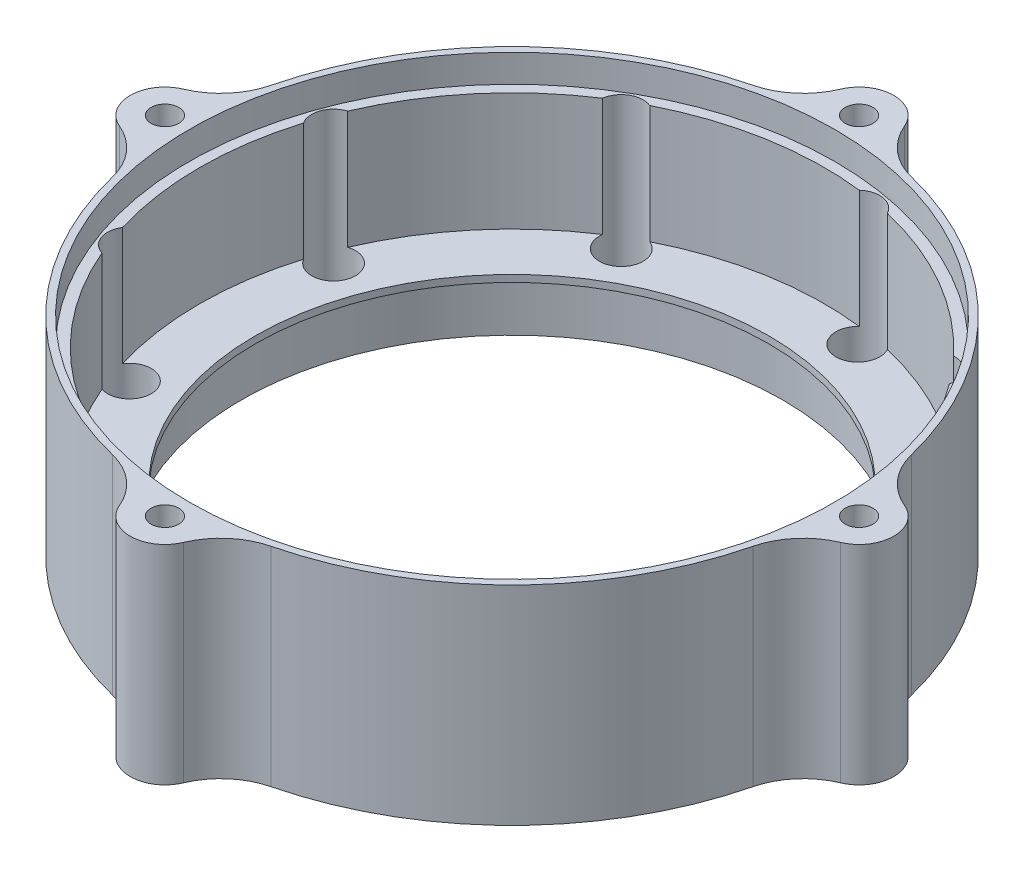
from build123d import *
from build123d.topology import SkipClean

# Parameters (mm, degrees)
SKETCH1_R            = 50
BOSS_EXTRUDE1_DEPTH  = 5
SKETCH2_R            = 3
BOSS_EXTRUDE2_DEPTH  = 30
SKETCH3_R            = 50
BOSS_EXTRUDE3_DEPTH  = 28
SKETCH4_R            = 39
CUT_EXTRUDE1_DEPTH   = 6
SKETCH5_R            = 3
CUT_EXTRUDE2_DEPTH   = 44
SKETCH6_R            = 50
SKETCH6_R_2          = 39
BOSS_EXTRUDE4_DEPTH  = 3
SKETCH7_R            = 47
SKETCH7_R_2          = 46
CUT_EXTRUDE3_DEPTH   = 4
SKETCH8_R            = 39
SKETCH8_R_2          = 37
BOSS_EXTRUDE5_DEPTH  = 1
SKETCH9_R            = 5
SKETCH9_R_2          = 2
BOSS_EXTRUDE6_DEPTH  = 33
FILLET1_R            = 5
SKETCH10_R           = 3.15
CUT_EXTRUDE6_DEPTH   = 2.5
SKETCH11_R           = 47.15
CUT_EXTRUDE7_DEPTH   = 4
SKETCH12_R           = 39
SKETCH12_R_2         = 3.15
BOSS_EXTRUDE7_DEPTH  = 7
SKETCH13_R           = 39
SKETCH13_R_2         = 37
BOSS_EXTRUDE9_DEPTH  = 1
SKETCH14_R           = 39
SKETCH14_R_2         = 37
CUT_EXTRUDE8_DEPTH   = 1
SKETCH15_R           = 3.15
BOSS_EXTRUDE10_DEPTH = 2.9
SKETCH16_R           = 57
CUT_EXTRUDE9_DEPTH   = 3
BOSS_EXTRUDE11_DEPTH = 17
CUT_EXTRUDE13_START  = -30
SKETCH18_R           = 47.5
SKETCH18_R_2         = 2
CUT_EXTRUDE13_DEPTH  = 30
SKETCH19_R           = 47.15
SKETCH19_R_2         = 46.15
BOSS_EXTRUDE12_DEPTH = 21
SKETCH20_R           = 46.5
SKETCH20_R_2         = 46.15
CUT_EXTRUDE14_DEPTH  = 4
SKETCH21_R           = 2
BOSS_EXTRUDE14_DEPTH = 30
FILLET2_R            = 10


with BuildPart() as part:
    # Sketch1 → Boss-Extrude1 (new body)
    with BuildSketch(Plane(origin=(0, 0, 0), x_dir=(1, 0, 0), z_dir=(0, 1, 0))):
        with Locations(Location((0, 0, 0), (0, 0, 270))):
            Circle(SKETCH1_R)
    extrude(amount=BOSS_EXTRUDE1_DEPTH)

    # Sketch2 → Boss-Extrude2 (add)
    with BuildSketch(Plane(origin=(0, 5, 0), x_dir=(1, 0, 0), z_dir=(0, 1, 0))):
        with Locations(Location((43, 0, 0), (0, 0, 270))):
            Circle(SKETCH2_R)
        with Locations(Location((32.939911054, -27.639867217, 0), (0, 0, 270))):
            Circle(SKETCH2_R)
        with Locations(Location((7.46687164, -42.34673338, 0), (0, 0, 270))):
            Circle(SKETCH2_R)
        with Locations(Location((-21.5, -37.239092363, 0), (0, 0, 270))):
            Circle(SKETCH2_R)
        with Locations(Location((-40.406782694, -14.706866163, 0), (0, 0, 270))):
            Circle(SKETCH2_R)
        with Locations(Location((-40.406782694, 14.706866163, 0), (0, 0, 270))):
            Circle(SKETCH2_R)
        with Locations(Location((-21.5, 37.239092363, 0), (0, 0, 270))):
            Circle(SKETCH2_R)
        with Locations(Location((7.46687164, 42.34673338, 0), (0, 0, 270))):
            Circle(SKETCH2_R)
        with Locations(Location((32.939911054, 27.639867217, 0), (0, 0, 270))):
            Circle(SKETCH2_R)
    extrude(amount=BOSS_EXTRUDE2_DEPTH)

    # Sketch3 → Boss-Extrude3 (add)
    with BuildSketch(Plane(origin=(0, 5, 0), x_dir=(1, 0, 0), z_dir=(0, 1, 0))):
        with Locations(Location((0, 0, 0), (0, 0, 270))):
            Circle(SKETCH3_R)
        with BuildLine():
            ThreePointArc((45.918604651, 2.735278211), (43.225860556, 15.732926593), (36.933894872, 27.42056545))
            ThreePointArc((36.933894872, 27.42056545), (36.004088827, 30.211017655), (33.417488986, 31.611254798))
            ThreePointArc((33.417488986, 31.611254798), (23, 39.837168574), (10.667405207, 44.746021791))
            ThreePointArc((10.667405207, 44.746021791), (8.16146435, 46.285964392), (5.27995883, 45.695973945))
            ThreePointArc((5.27995883, 45.695973945), (-7.987816173, 45.301156639), (-20.590481909, 41.13431724))
            ThreePointArc((-20.590481909, 41.13431724), (-23.5, 40.703193978), (-25.328122743, 38.399039029))
            ThreePointArc((-25.328122743, 38.399039029), (-35.238044383, 29.568230046), (-42.213853702, 18.275408495))
            ThreePointArc((-42.213853702, 18.275408495), (-44.165553177, 16.074946736), (-44.084894193, 13.134766994))
            ThreePointArc((-44.084894193, 13.134766994), (-46, 0), (-44.084894193, -13.134766994))
            ThreePointArc((-44.084894193, -13.134766994), (-44.165553177, -16.074946736), (-42.213853702, -18.275408495))
            ThreePointArc((-42.213853702, -18.275408495), (-35.238044383, -29.568230046), (-25.328122743, -38.399039029))
            ThreePointArc((-25.328122743, -38.399039029), (-23.5, -40.703193978), (-20.590481909, -41.13431724))
            ThreePointArc((-20.590481909, -41.13431724), (-7.987816173, -45.301156639), (5.27995883, -45.695973945))
            ThreePointArc((5.27995883, -45.695973945), (8.16146435, -46.285964392), (10.667405207, -44.746021791))
            ThreePointArc((10.667405207, -44.746021791), (23, -39.837168574), (33.417488986, -31.611254798))
            ThreePointArc((33.417488986, -31.611254798), (36.004088827, -30.211017655), (36.933894872, -27.42056545))
            ThreePointArc((36.933894872, -27.42056545), (43.225860556, -15.732926593), (45.918604651, -2.735278211))
            ThreePointArc((45.918604651, -2.735278211), (47, 0), (45.918604651, 2.735278211))
        make_face(mode=Mode.SUBTRACT)
    extrude(amount=BOSS_EXTRUDE3_DEPTH)

    # Sketch4 → Cut-Extrude1 (cut)
    with BuildSketch(Plane(origin=(0, 5, 0), x_dir=(1, 0, 0), z_dir=(0, 1, 0))):
        with Locations(Location((0, 0, 0), (0, 0, 270))):
            Circle(SKETCH4_R)
    extrude(amount=-CUT_EXTRUDE1_DEPTH, mode=Mode.SUBTRACT)

    # Sketch5 → Cut-Extrude2 (cut, symmetric)
    with BuildSketch(Plane(origin=(0, 5, 0), x_dir=(1, 0, 0), z_dir=(0, 1, 0))):
        with Locations(Location((43, 0, 0), (0, 0, 270))):
            Circle(SKETCH5_R)
        with Locations(Location((32.939911054, -27.639867217, 0), (0, 0, 270))):
            Circle(SKETCH5_R)
        with Locations(Location((7.46687164, -42.34673338, 0), (0, 0, 270))):
            Circle(SKETCH5_R)
        with Locations(Location((-21.5, -37.239092363, 0), (0, 0, 270))):
            Circle(SKETCH5_R)
        with Locations(Location((-40.406782694, -14.706866163, 0), (0, 0, 270))):
            Circle(SKETCH5_R)
        with Locations(Location((-40.406782694, 14.706866163, 0), (0, 0, 270))):
            Circle(SKETCH5_R)
        with Locations(Location((-21.5, 37.239092363, 0), (0, 0, 270))):
            Circle(SKETCH5_R)
        with Locations(Location((7.46687164, 42.34673338, 0), (0, 0, 270))):
            Circle(SKETCH5_R)
        with Locations(Location((32.939911054, 27.639867217, 0), (0, 0, 270))):
            Circle(SKETCH5_R)
    extrude(amount=CUT_EXTRUDE2_DEPTH, both=True, mode=Mode.SUBTRACT)

    # Sketch6 → Boss-Extrude4 (add)
    with BuildSketch(Plane.XZ):
        with Locations(Location((0, 0, 0), (0, 0, 90))):
            Circle(SKETCH6_R)
        with Locations(Location((0, 0, 0), (0, 0, 90))):
            Circle(SKETCH6_R_2, mode=Mode.SUBTRACT)
    extrude(amount=-BOSS_EXTRUDE4_DEPTH)

    # Sketch7 → Cut-Extrude3 (cut)
    with BuildSketch(Plane(origin=(0, 33, 0), x_dir=(1, 0, 0), z_dir=(0, 1, 0))):
        with Locations(Location((0, 0, 0), (0, 0, 270))):
            Circle(SKETCH7_R)
        Circle(SKETCH7_R_2, mode=Mode.SUBTRACT)
    extrude(amount=-CUT_EXTRUDE3_DEPTH, mode=Mode.SUBTRACT)

    # Sketch8 → Boss-Extrude5 (add)
    with BuildSketch(Plane.XZ):
        with Locations(Location((0, 0, 0), (0, 0, 90))):
            Circle(SKETCH8_R)
        with Locations(Location((0, 0, 0), (0, 0, 270))):
            Circle(SKETCH8_R_2, mode=Mode.SUBTRACT)
    extrude(amount=-BOSS_EXTRUDE5_DEPTH)

    # Sketch9 → Boss-Extrude6 (add)
    with BuildSketch(Plane(origin=(0, 33, 0), x_dir=(1, 0, 0), z_dir=(0, 1, 0))):
        with Locations((52, 0)):
            Circle(SKETCH9_R)
        with Locations(Location((52, 0, 0), (0, 0, 270))):
            Circle(SKETCH9_R_2, mode=Mode.SUBTRACT)
        with Locations((-52, 0)):
            Circle(SKETCH9_R)
        with Locations(Location((-52, 0, 0), (0, 0, 270))):
            Circle(SKETCH9_R_2, mode=Mode.SUBTRACT)
        with Locations((0, 52)):
            Circle(SKETCH9_R)
        with Locations(Location((0, 52, 0), (0, 0, 270))):
            Circle(SKETCH9_R_2, mode=Mode.SUBTRACT)
        with Locations((0, -52)):
            Circle(SKETCH9_R)
        with Locations(Location((0, -52, 0), (0, 0, 270))):
            Circle(SKETCH9_R_2, mode=Mode.SUBTRACT)
    extrude(amount=-BOSS_EXTRUDE6_DEPTH)

    # Fillet1
    fillet1_edges = [part.edges().sort_by_distance(p)[0] for p in [
        (49.798076923, 16.5, 4.489046086),
        (49.798076923, 16.5, -4.489046086),
        (-49.798076923, 16.5, -4.489046086),
        (-49.798076923, 16.5, 4.489046086),
        (4.489046086, 16.5, -49.798076923),
        (-4.489046086, 16.5, -49.798076923),
        (-4.489046086, 16.5, 49.798076923),
        (4.489046086, 16.5, 49.798076923),
    ]]
    fillet(fillet1_edges, radius=FILLET1_R)

    # Sketch10 → Cut-Extrude6 (cut)
    with BuildSketch(Plane(origin=(0, 5, 0), x_dir=(1, 0, 0), z_dir=(0, 1, 0))):
        with Locations(Location((32.939911054, -27.639867217, 0), (0, 0, 270))):
            Circle(SKETCH10_R)
        with Locations(Location((43, 0, 0), (0, 0, 270))):
            Circle(SKETCH10_R)
        with Locations(Location((7.46687164, -42.34673338, 0), (0, 0, 270))):
            Circle(SKETCH10_R)
        with Locations(Location((-21.5, -37.239092363, 0), (0, 0, 270))):
            Circle(SKETCH10_R)
        with Locations(Location((-40.406782694, -14.706866163, 0), (0, 0, 270))):
            Circle(SKETCH10_R)
        with Locations(Location((-40.406782694, 14.706866163, 0), (0, 0, 270))):
            Circle(SKETCH10_R)
        with Locations(Location((-21.5, 37.239092363, 0), (0, 0, 270))):
            Circle(SKETCH10_R)
        with Locations(Location((7.46687164, 42.34673338, 0), (0, 0, 270))):
            Circle(SKETCH10_R)
        with Locations(Location((32.939911054, 27.639867217, 0), (0, 0, 270))):
            Circle(SKETCH10_R)
    extrude(amount=-CUT_EXTRUDE6_DEPTH, mode=Mode.SUBTRACT)

    # Sketch11 → Cut-Extrude7 (cut)
    with BuildSketch(Plane(origin=(0, 33, 0), x_dir=(1, 0, 0), z_dir=(0, 1, 0))):
        with Locations(Location((0, 0, 0), (0, 0, 270))):
            Circle(SKETCH11_R)
    extrude(amount=-CUT_EXTRUDE7_DEPTH, mode=Mode.SUBTRACT)

    # Sketch12 → Boss-Extrude7 (add)
    with BuildSketch(Plane(origin=(0, 5, 0), x_dir=(1, 0, 0), z_dir=(0, 1, 0))):
        with BuildLine():
            ThreePointArc((36.933894872, -27.42056545), (43.225860556, -15.732926593), (45.918604651, -2.735278211))
            ThreePointArc((45.918604651, -2.735278211), (47, 0), (45.918604651, 2.735278211))
            ThreePointArc((45.918604651, 2.735278211), (43.225860556, 15.732926593), (36.933894872, 27.42056545))
            ThreePointArc((36.933894872, 27.42056545), (36.004088827, 30.211017655), (33.417488986, 31.611254798))
            ThreePointArc((33.417488986, 31.611254798), (23, 39.837168574), (10.667405207, 44.746021791))
            ThreePointArc((10.667405207, 44.746021791), (8.16146435, 46.285964392), (5.27995883, 45.695973945))
            ThreePointArc((5.27995883, 45.695973945), (-7.987816173, 45.301156639), (-20.590481909, 41.13431724))
            ThreePointArc((-20.590481909, 41.13431724), (-23.5, 40.703193978), (-25.328122743, 38.399039029))
            ThreePointArc((-25.328122743, 38.399039029), (-35.238044383, 29.568230046), (-42.213853702, 18.275408495))
            ThreePointArc((-42.213853702, 18.275408495), (-44.165553177, 16.074946736), (-44.084894193, 13.134766994))
            ThreePointArc((-44.084894193, 13.134766994), (-46, 0), (-44.084894193, -13.134766994))
            ThreePointArc((-44.084894193, -13.134766994), (-44.165553177, -16.074946736), (-42.213853702, -18.275408495))
            ThreePointArc((-42.213853702, -18.275408495), (-35.238044383, -29.568230046), (-25.328122743, -38.399039029))
            ThreePointArc((-25.328122743, -38.399039029), (-23.5, -40.703193978), (-20.590481909, -41.13431724))
            ThreePointArc((-20.590481909, -41.13431724), (-7.987816173, -45.301156639), (5.27995883, -45.695973945))
            ThreePointArc((5.27995883, -45.695973945), (8.16146435, -46.285964392), (10.667405207, -44.746021791))
            ThreePointArc((10.667405207, -44.746021791), (23, -39.837168574), (33.417488986, -31.611254798))
            ThreePointArc((33.417488986, -31.611254798), (36.004088827, -30.211017655), (36.933894872, -27.42056545))
        make_face()
        with Locations(Location((0, 0, 0), (0, 0, 270))):
            Circle(SKETCH12_R, mode=Mode.SUBTRACT)
        with Locations(Location((32.939911054, -27.639867217, 0), (0, 0, 270))):
            Circle(SKETCH12_R_2, mode=Mode.SUBTRACT)
        with Locations(Location((43, 0, 0), (0, 0, 270))):
            Circle(SKETCH12_R_2, mode=Mode.SUBTRACT)
        with Locations(Location((7.46687164, -42.34673338, 0), (0, 0, 270))):
            Circle(SKETCH12_R_2, mode=Mode.SUBTRACT)
        with Locations(Location((-21.5, -37.239092363, 0), (0, 0, 270))):
            Circle(SKETCH12_R_2, mode=Mode.SUBTRACT)
        with Locations(Location((-40.406782694, -14.706866163, 0), (0, 0, 270))):
            Circle(SKETCH12_R_2, mode=Mode.SUBTRACT)
        with Locations(Location((-40.406782694, 14.706866163, 0), (0, 0, 270))):
            Circle(SKETCH12_R_2, mode=Mode.SUBTRACT)
        with Locations(Location((-21.5, 37.239092363, 0), (0, 0, 270))):
            Circle(SKETCH12_R_2, mode=Mode.SUBTRACT)
        with Locations(Location((7.46687164, 42.34673338, 0), (0, 0, 270))):
            Circle(SKETCH12_R_2, mode=Mode.SUBTRACT)
        with Locations(Location((32.939911054, 27.639867217, 0), (0, 0, 270))):
            Circle(SKETCH12_R_2, mode=Mode.SUBTRACT)
    extrude(amount=BOSS_EXTRUDE7_DEPTH)

    # Sketch13 → Boss-Extrude9 (add)
    with BuildSketch(Plane(origin=(0, 12, 0), x_dir=(1, 0, 0), z_dir=(0, 1, 0))):
        with Locations(Location((0, 0, 0), (0, 0, 270))):
            Circle(SKETCH13_R)
        with Locations(Location((0, 0, 0), (0, 0, 90))):
            Circle(SKETCH13_R_2, mode=Mode.SUBTRACT)
    extrude(amount=-BOSS_EXTRUDE9_DEPTH)

    # Sketch14 → Cut-Extrude8 (cut)
    with BuildSketch(Plane.XZ):
        with Locations(Location((0, 0, 0), (0, 0, 90))):
            Circle(SKETCH14_R)
        with Locations(Location((0, 0, 0), (0, 0, 90))):
            Circle(SKETCH14_R_2, mode=Mode.SUBTRACT)
    extrude(amount=-CUT_EXTRUDE8_DEPTH, mode=Mode.SUBTRACT)

    # Sketch15 → Boss-Extrude10 (add)
    with BuildSketch(Plane(origin=(0, 2.5, 0), x_dir=(1, 0, 0), z_dir=(0, 1, 0))):
        with Locations(Location((43, 0, 0), (0, 0, 270))):
            Circle(SKETCH15_R)
        with Locations(Location((32.939911054, -27.639867217, 0), (0, 0, 270))):
            Circle(SKETCH15_R)
        with Locations(Location((7.46687164, -42.34673338, 0), (0, 0, 270))):
            Circle(SKETCH15_R)
        with Locations(Location((-21.5, -37.239092363, 0), (0, 0, 270))):
            Circle(SKETCH15_R)
        with Locations(Location((-40.406782694, -14.706866163, 0), (0, 0, 270))):
            Circle(SKETCH15_R)
        with Locations(Location((-40.406782694, 14.706866163, 0), (0, 0, 270))):
            Circle(SKETCH15_R)
        with Locations(Location((-21.5, 37.239092363, 0), (0, 0, 270))):
            Circle(SKETCH15_R)
        with Locations(Location((7.46687164, 42.34673338, 0), (0, 0, 270))):
            Circle(SKETCH15_R)
        with Locations(Location((32.939911054, 27.639867217, 0), (0, 0, 270))):
            Circle(SKETCH15_R)
    extrude(amount=BOSS_EXTRUDE10_DEPTH)

    # Sketch16 → Cut-Extrude9 (cut)
    with BuildSketch(Plane(origin=(0, 0, 0), x_dir=(-1, 0, 0), z_dir=(0, -1, 0))):
        Circle(SKETCH16_R)
    extrude(amount=-CUT_EXTRUDE9_DEPTH, mode=Mode.SUBTRACT)

    # Sketch17 → Boss-Extrude11 (add)
    with BuildSketch(Plane(origin=(0, 29, 0), x_dir=(1, 0, 0), z_dir=(0, 1, 0))):
        with BuildLine():
            ThreePointArc((36.933894872, -27.42056545), (43.225860556, -15.732926593), (45.918604651, -2.735278211))
            ThreePointArc((45.918604651, -2.735278211), (47, 0), (45.918604651, 2.735278211))
            ThreePointArc((45.918604651, 2.735278211), (43.225860556, 15.732926593), (36.933894872, 27.42056545))
            ThreePointArc((36.933894872, 27.42056545), (36.004088827, 30.211017655), (33.417488986, 31.611254798))
            ThreePointArc((33.417488986, 31.611254798), (23, 39.837168574), (10.667405207, 44.746021791))
            ThreePointArc((10.667405207, 44.746021791), (8.16146435, 46.285964392), (5.27995883, 45.695973945))
            ThreePointArc((5.27995883, 45.695973945), (-7.987816173, 45.301156639), (-20.590481909, 41.13431724))
            ThreePointArc((-20.590481909, 41.13431724), (-23.5, 40.703193978), (-25.328122743, 38.399039029))
            ThreePointArc((-25.328122743, 38.399039029), (-35.238044383, 29.568230046), (-42.213853702, 18.275408495))
            ThreePointArc((-42.213853702, 18.275408495), (-44.165553177, 16.074946736), (-44.084894193, 13.134766994))
            ThreePointArc((-44.084894193, 13.134766994), (-46, 0), (-44.084894193, -13.134766994))
            ThreePointArc((-44.084894193, -13.134766994), (-44.165553177, -16.074946736), (-42.213853702, -18.275408495))
            ThreePointArc((-42.213853702, -18.275408495), (-35.238044383, -29.568230046), (-25.328122743, -38.399039029))
            ThreePointArc((-25.328122743, -38.399039029), (-23.5, -40.703193978), (-20.590481909, -41.13431724))
            ThreePointArc((-20.590481909, -41.13431724), (-7.987816173, -45.301156639), (5.27995883, -45.695973945))
            ThreePointArc((5.27995883, -45.695973945), (8.16146435, -46.285964392), (10.667405207, -44.746021791))
            ThreePointArc((10.667405207, -44.746021791), (23, -39.837168574), (33.417488986, -31.611254798))
            ThreePointArc((33.417488986, -31.611254798), (36.004088827, -30.211017655), (36.933894872, -27.42056545))
        make_face()
        with BuildLine():
            ThreePointArc((36.018898513, 26.974783593), (42.286167935, 15.39090645), (44.931133721, 2.488618603))
            ThreePointArc((44.931133721, 2.488618603), (45.828919513, 1.385537581), (46.15, 0))
            ThreePointArc((46.15, 0), (45.828919513, -1.385537581), (44.931133721, -2.488618603))
            ThreePointArc((44.931133721, -2.488618603), (42.286167935, -15.39090645), (36.018898513, -26.974783593))
            ThreePointArc((36.018898513, -26.974783593), (36.072107607, -27.305435233), (36.089911054, -27.639867217))
            ThreePointArc((36.089911054, -27.639867217), (35.124344083, -29.909394115), (32.819592107, -30.787568497))
            ThreePointArc((32.819592107, -30.787568497), (22.5, -38.97114317), (10.253020386, -43.816384755))
            ThreePointArc((10.253020386, -43.816384755), (8.013863399, -45.448877802), (5.351398596, -44.680672925))
            ThreePointArc((5.351398596, -44.680672925), (-7.814167995, -44.316348886), (-20.31035993, -40.155812525))
            ThreePointArc((-20.31035993, -40.155812525), (-23.075, -39.967072385), (-24.620773791, -37.667193922))
            ThreePointArc((-24.620773791, -37.667193922), (-34.47199994, -28.925442436), (-41.37029711, -17.705889332))
            ThreePointArc((-41.37029711, -17.705889332), (-43.366814449, -15.784229614), (-43.072612492, -13.028816258))
            ThreePointArc((-43.072612492, -13.028816258), (-45, 0), (-43.072612492, 13.028816258))
            ThreePointArc((-43.072612492, 13.028816258), (-43.366814449, 15.784229614), (-41.37029711, 17.705889332))
            ThreePointArc((-41.37029711, 17.705889332), (-34.47199994, 28.925442436), (-24.620773791, 37.667193922))
            ThreePointArc((-24.620773791, 37.667193922), (-23.075, 39.967072385), (-20.31035993, 40.155812525))
            ThreePointArc((-20.31035993, 40.155812525), (-7.814167995, 44.316348886), (5.351398596, 44.680672925))
            ThreePointArc((5.351398596, 44.680672925), (8.013863399, 45.448877802), (10.253020386, 43.816384755))
            ThreePointArc((10.253020386, 43.816384755), (22.5, 38.97114317), (32.819592107, 30.787568497))
            ThreePointArc((32.819592107, 30.787568497), (35.124344083, 29.909394115), (36.089911054, 27.639867217))
            ThreePointArc((36.089911054, 27.639867217), (36.072107607, 27.305435233), (36.018898513, 26.974783593))
        make_face(mode=Mode.SUBTRACT)
    extrude(amount=-BOSS_EXTRUDE11_DEPTH)

    # Sketch18 → Cut-Extrude13 (cut)
    with BuildSketch(Plane(origin=(0, 33, 0), x_dir=(1, 0, 0), z_dir=(0, 1, 0)).offset(CUT_EXTRUDE13_START)):
        with BuildLine():
            add(Edge.make_bspline(
                [(53.0625, -4.885805333), (52.836073182, -4.935045627), (52.60866978, -4.997686057), (52.381651265, -5.074241405), (52.156546198, -5.165006302), (51.934986665, -5.269967693), (51.501885278, -5.507764581), (51.290356485, -5.640638601), (51.085615173, -5.787065735), (50.889258423, -5.946379033), (50.702733406, -6.117577737), (50.352444061, -6.480535262), (50.188590734, -6.672210163), (50.036862124, -6.873218404), (49.898196618, -7.082096871), (49.77319943, -7.297246207), (49.550370532, -7.738331674), (49.452724639, -7.964331149), (49.369507547, -8.193413917), (49.300676289, -8.423927884), (49.245878786, -8.654336895), (49.204545455, -8.883282423)],
                knots=[0, 0, 0, 0, 0, 0, 0, 0.249829575, 0.249829575, 0.249829575, 0.249829575, 0.249829575, 0.5, 0.5, 0.5, 0.5, 0.5, 0.749170225, 0.749170225, 0.749170225, 0.749170225, 0.749170225, 1, 1, 1, 1, 1, 1, 1], degree=6))
            ThreePointArc((53.0625, -4.885805333), (57, 0), (53.0625, 4.885805333))
            add(Edge.make_bspline(
                [(49.204545455, 8.883282423), (49.245713967, 8.655249829), (49.300239483, 8.425765409), (49.368684808, 8.196171496), (49.451398669, 7.967985224), (49.548425977, 7.742838112), (49.770692859, 7.301565403), (49.895971396, 7.085451489), (50.035035531, 6.875639486), (50.18727545, 6.673749151), (50.351742417, 6.481262281), (50.702031762, 6.118304756), (50.887767114, 5.947748139), (51.083260483, 5.788977152), (51.287083003, 5.642981547), (51.497657818, 5.510422952), (51.930552122, 5.272071051), (52.152941515, 5.166461197), (52.378924642, 5.07516155), (52.606848925, 4.998187841), (52.835166676, 4.935242762), (53.0625, 4.885805333)],
                knots=[0, 0, 0, 0, 0, 0, 0, 0.249829575, 0.249829575, 0.249829575, 0.249829575, 0.249829575, 0.5, 0.5, 0.5, 0.5, 0.5, 0.749170225, 0.749170225, 0.749170225, 0.749170225, 0.749170225, 1, 1, 1, 1, 1, 1, 1], degree=6))
            ThreePointArc((49.204545455, 8.883282423), (35.355339059, 35.355339059), (8.883282423, 49.204545455))
            add(Edge.make_bspline(
                [(4.885805333, 53.0625), (4.935045627, 52.836073182), (4.997686057, 52.60866978), (5.074241405, 52.381651265), (5.165006302, 52.156546198), (5.269967693, 51.934986665), (5.507764581, 51.501885278), (5.640638601, 51.290356485), (5.787065735, 51.085615173), (5.946379033, 50.889258423), (6.117577737, 50.702733406), (6.480535262, 50.352444061), (6.672210163, 50.188590734), (6.873218404, 50.036862124), (7.082096871, 49.898196618), (7.297246207, 49.77319943), (7.738331674, 49.550370532), (7.964331149, 49.452724639), (8.193413917, 49.369507547), (8.423927884, 49.300676289), (8.654336895, 49.245878786), (8.883282423, 49.204545455)],
                knots=[0, 0, 0, 0, 0, 0, 0, 0.249829575, 0.249829575, 0.249829575, 0.249829575, 0.249829575, 0.5, 0.5, 0.5, 0.5, 0.5, 0.749170225, 0.749170225, 0.749170225, 0.749170225, 0.749170225, 1, 1, 1, 1, 1, 1, 1], degree=6))
            ThreePointArc((4.885805333, 53.0625), (0, 57), (-4.885805333, 53.0625))
            add(Edge.make_bspline(
                [(-8.883282423, 49.204545455), (-8.655249829, 49.245713967), (-8.425765409, 49.300239483), (-8.196171496, 49.368684808), (-7.967985224, 49.451398669), (-7.742838112, 49.548425977), (-7.301565403, 49.770692859), (-7.085451489, 49.895971396), (-6.875639486, 50.035035531), (-6.673749151, 50.18727545), (-6.481262281, 50.351742417), (-6.118304756, 50.702031762), (-5.947748139, 50.887767114), (-5.788977152, 51.083260483), (-5.642981547, 51.287083003), (-5.510422952, 51.497657818), (-5.272071051, 51.930552122), (-5.166461197, 52.152941515), (-5.07516155, 52.378924642), (-4.998187841, 52.606848925), (-4.935242762, 52.835166676), (-4.885805333, 53.0625)],
                knots=[0, 0, 0, 0, 0, 0, 0, 0.249829575, 0.249829575, 0.249829575, 0.249829575, 0.249829575, 0.5, 0.5, 0.5, 0.5, 0.5, 0.749170225, 0.749170225, 0.749170225, 0.749170225, 0.749170225, 1, 1, 1, 1, 1, 1, 1], degree=6))
            ThreePointArc((-8.883282423, 49.204545455), (-35.355339059, 35.355339059), (-49.204545455, 8.883282423))
            add(Edge.make_bspline(
                [(-53.0625, 4.885805333), (-52.836073182, 4.935045627), (-52.60866978, 4.997686057), (-52.381651265, 5.074241405), (-52.156546198, 5.165006302), (-51.934986665, 5.269967693), (-51.501885278, 5.507764581), (-51.290356485, 5.640638601), (-51.085615173, 5.787065735), (-50.889258423, 5.946379033), (-50.702733406, 6.117577737), (-50.352444061, 6.480535262), (-50.188590734, 6.672210163), (-50.036862124, 6.873218404), (-49.898196618, 7.082096871), (-49.77319943, 7.297246207), (-49.550370532, 7.738331674), (-49.452724639, 7.964331149), (-49.369507547, 8.193413917), (-49.300676289, 8.423927884), (-49.245878786, 8.654336895), (-49.204545455, 8.883282423)],
                knots=[0, 0, 0, 0, 0, 0, 0, 0.249829575, 0.249829575, 0.249829575, 0.249829575, 0.249829575, 0.5, 0.5, 0.5, 0.5, 0.5, 0.749170225, 0.749170225, 0.749170225, 0.749170225, 0.749170225, 1, 1, 1, 1, 1, 1, 1], degree=6))
            ThreePointArc((-53.0625, 4.885805333), (-57, 0), (-53.0625, -4.885805333))
            add(Edge.make_bspline(
                [(-49.204545455, -8.883282423), (-49.245713967, -8.655249829), (-49.300239483, -8.425765409), (-49.368684808, -8.196171496), (-49.451398669, -7.967985224), (-49.548425977, -7.742838112), (-49.770692859, -7.301565403), (-49.895971396, -7.085451489), (-50.035035531, -6.875639486), (-50.18727545, -6.673749151), (-50.351742417, -6.481262281), (-50.702031762, -6.118304756), (-50.887767114, -5.947748139), (-51.083260483, -5.788977152), (-51.287083003, -5.642981547), (-51.497657818, -5.510422952), (-51.930552122, -5.272071051), (-52.152941515, -5.166461197), (-52.378924642, -5.07516155), (-52.606848925, -4.998187841), (-52.835166676, -4.935242762), (-53.0625, -4.885805333)],
                knots=[0, 0, 0, 0, 0, 0, 0, 0.249829575, 0.249829575, 0.249829575, 0.249829575, 0.249829575, 0.5, 0.5, 0.5, 0.5, 0.5, 0.749170225, 0.749170225, 0.749170225, 0.749170225, 0.749170225, 1, 1, 1, 1, 1, 1, 1], degree=6))
            ThreePointArc((-49.204545455, -8.883282423), (-35.355339059, -35.355339059), (-8.883282423, -49.204545455))
            add(Edge.make_bspline(
                [(-8.883282423, -49.204545455), (-8.655249829, -49.245713967), (-8.425765409, -49.300239483), (-8.196171496, -49.368684808), (-7.967985224, -49.451398669), (-7.742838112, -49.548425977), (-7.301565403, -49.770692859), (-7.085451489, -49.895971396), (-6.875639486, -50.035035531), (-6.673749151, -50.18727545), (-6.481262281, -50.351742417), (-6.118304756, -50.702031762), (-5.947748139, -50.887767114), (-5.788977152, -51.083260483), (-5.642981547, -51.287083003), (-5.510422952, -51.497657818), (-5.272071051, -51.930552122), (-5.166461197, -52.152941515), (-5.07516155, -52.378924642), (-4.998187841, -52.606848925), (-4.935242762, -52.835166676), (-4.885805333, -53.0625)],
                knots=[0, 0, 0, 0, 0, 0, 0, 0.249829575, 0.249829575, 0.249829575, 0.249829575, 0.249829575, 0.5, 0.5, 0.5, 0.5, 0.5, 0.749170225, 0.749170225, 0.749170225, 0.749170225, 0.749170225, 1, 1, 1, 1, 1, 1, 1], degree=6))
            ThreePointArc((-4.885805333, -53.0625), (0, -57), (4.885805333, -53.0625))
            add(Edge.make_bspline(
                [(8.883282423, -49.204545455), (8.655249829, -49.245713967), (8.425765409, -49.300239483), (8.196171496, -49.368684808), (7.967985224, -49.451398669), (7.742838112, -49.548425977), (7.301565403, -49.770692859), (7.085451489, -49.895971396), (6.875639486, -50.035035531), (6.673749151, -50.18727545), (6.481262281, -50.351742417), (6.118304756, -50.702031762), (5.947748139, -50.887767114), (5.788977152, -51.083260483), (5.642981547, -51.287083003), (5.510422952, -51.497657818), (5.272071051, -51.930552122), (5.166461197, -52.152941515), (5.07516155, -52.378924642), (4.998187841, -52.606848925), (4.935242762, -52.835166676), (4.885805333, -53.0625)],
                knots=[0, 0, 0, 0, 0, 0, 0, 0.249829575, 0.249829575, 0.249829575, 0.249829575, 0.249829575, 0.5, 0.5, 0.5, 0.5, 0.5, 0.749170225, 0.749170225, 0.749170225, 0.749170225, 0.749170225, 1, 1, 1, 1, 1, 1, 1], degree=6))
            ThreePointArc((8.883282423, -49.204545455), (35.355339059, -35.355339059), (49.204545455, -8.883282423))
        make_face()
        with Locations(Location((0, 0, 0), (0, 0, 270))):
            Circle(SKETCH18_R, mode=Mode.SUBTRACT)
        with Locations((52, 0)):
            Circle(SKETCH18_R_2, mode=Mode.SUBTRACT)
        with Locations((0, 52)):
            Circle(SKETCH18_R_2, mode=Mode.SUBTRACT)
        with Locations((0, -52)):
            Circle(SKETCH18_R_2, mode=Mode.SUBTRACT)
        with Locations((-52, 0)):
            Circle(SKETCH18_R_2, mode=Mode.SUBTRACT)
    extrude(amount=CUT_EXTRUDE13_DEPTH, mode=Mode.SUBTRACT)

    # Sketch19 → Boss-Extrude12 (add)
    with SkipClean():  # the faces are left unmerged after this step: merging them gives an invalid solid
        with BuildSketch(Plane(origin=(0, 12, 0), x_dir=(1, 0, 0), z_dir=(0, 1, 0))):
            Circle(SKETCH19_R)
            with Locations(Location((0, 0, 0), (0, 0, 80))):
                Circle(SKETCH19_R_2, mode=Mode.SUBTRACT)
        extrude(amount=BOSS_EXTRUDE12_DEPTH)

    # Sketch20 → Cut-Extrude14 (cut)
    with BuildSketch(Plane(origin=(0, 33, 0), x_dir=(1, 0, 0), z_dir=(0, 1, 0))):
        with Locations(Location((0, 0, 0), (0, 0, 270))):
            Circle(SKETCH20_R)
        Circle(SKETCH20_R_2, mode=Mode.SUBTRACT)
    extrude(amount=-CUT_EXTRUDE14_DEPTH, mode=Mode.SUBTRACT)

    # Sketch21 → Boss-Extrude14 (add)
    with BuildSketch(Plane(origin=(0, 33, 0), x_dir=(1, 0, 0), z_dir=(0, 1, 0))):
        with BuildLine():
            ThreePointArc((47.3125, -4.216318744), (55, 0), (47.3125, 4.216318744))
            ThreePointArc((47.3125, 4.216318744), (47.5, 0), (47.3125, -4.216318744))
        make_face()
        with Locations(Location((50, 0, 0), (0, 0, 270))):
            Circle(SKETCH21_R, mode=Mode.SUBTRACT)
        with BuildLine():
            ThreePointArc((-4.216318744, 47.3125), (0, 47.5), (4.216318744, 47.3125))
            ThreePointArc((4.216318744, 47.3125), (0, 55), (-4.216318744, 47.3125))
        make_face()
        with Locations(Location((0, 50, 0), (0, 0, 270))):
            Circle(SKETCH21_R, mode=Mode.SUBTRACT)
        with BuildLine():
            ThreePointArc((-4.216318744, -47.3125), (0, -55), (4.216318744, -47.3125))
            ThreePointArc((4.216318744, -47.3125), (0, -47.5), (-4.216318744, -47.3125))
        make_face()
        with Locations(Location((0, -50, 0), (0, 0, 270))):
            Circle(SKETCH21_R, mode=Mode.SUBTRACT)
        with BuildLine():
            ThreePointArc((-47.3125, -4.216318744), (-47.5, 0), (-47.3125, 4.216318744))
            ThreePointArc((-47.3125, 4.216318744), (-55, 0), (-47.3125, -4.216318744))
        make_face()
        with Locations(Location((-50, 0, 0), (0, 0, 270))):
            Circle(SKETCH21_R, mode=Mode.SUBTRACT)
    extrude(amount=-BOSS_EXTRUDE14_DEPTH)

    # Fillet2
    fillet2_edges = [part.edges().sort_by_distance(p)[0] for p in [
        (-47.3125, 18, 4.216318744),
        (-47.3125, 18, -4.216318744),
        (4.216318744, 18, 47.3125),
        (-4.216318744, 18, 47.3125),
        (47.3125, 18, -4.216318744),
        (47.3125, 18, 4.216318744),
        (-4.216318744, 18, -47.3125),
        (4.216318744, 18, -47.3125),
    ]]
    fillet(fillet2_edges, radius=FILLET2_R)


solid = part.part
